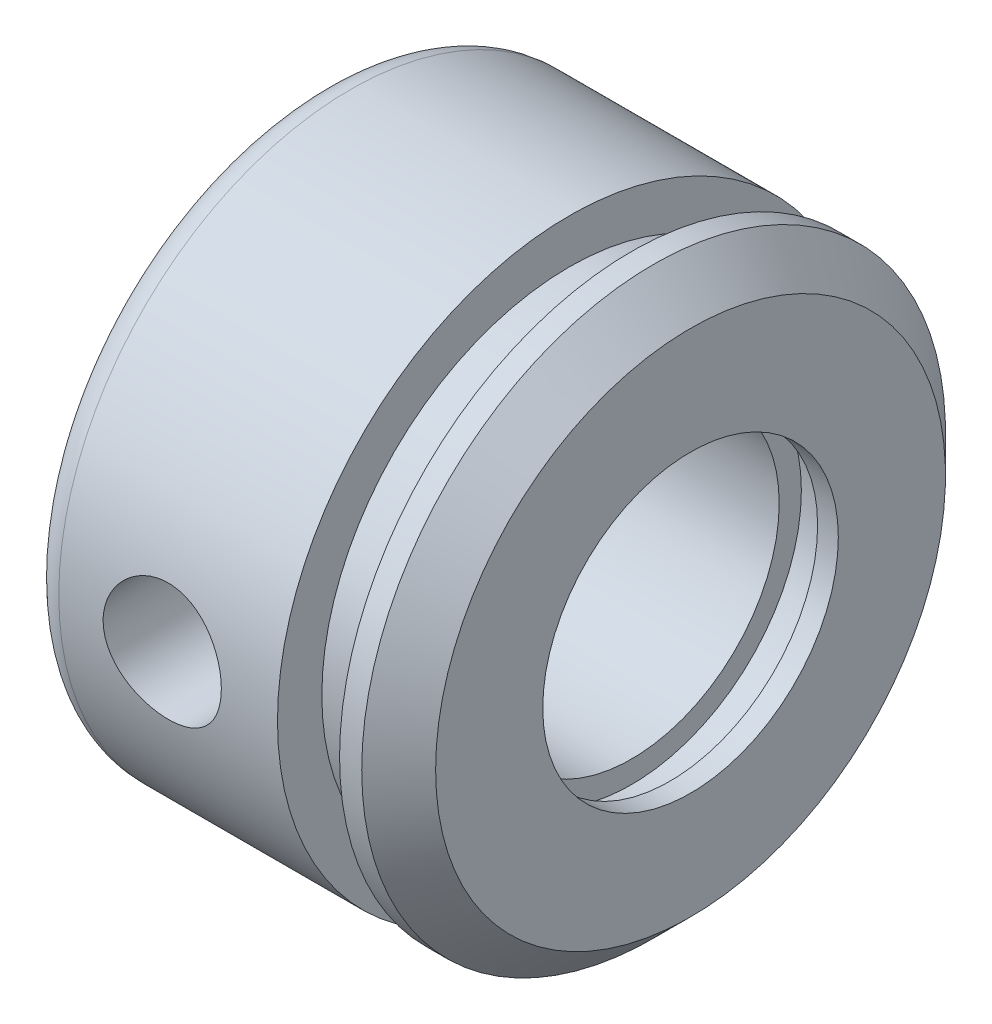
from build123d import *

# Parameters (mm, degrees)
ESQUISSE2_R                  = 4
ENL_V_MAT_EXTRU_1_DEPTH      = 20.75
ENL_V_MAT_EXTRU_1_DEPTH_BACK = 20.75
CONG_2_R                     = 2


with BuildPart() as part:
    # Esquisse1 → Base-Révolution (revolve)
    with BuildSketch(Plane.XY):
        Polygon((-24, 10), (-24, 19.75), (-7.2, 19.75), (-7.2, 16.75), (-3, 16.75), (-3, 19.75), (-1.5, 19.75), (1, 17.25), (1, 10), (-0.4, 10), (-0.4, 11.5), (-3, 11.5), (-3, 10), align=None)
    revolve(axis=Axis((-92, 0, 0), (1, 0, 0)))

    # Esquisse2 → Enlèv. mat.-Extru.1 (cut, two sides)
    with BuildSketch(Plane.XY) as enl_v_mat_extru_1_sk:
        with Locations((-15, 0)):
            Circle(ESQUISSE2_R)
    extrude(amount=ENL_V_MAT_EXTRU_1_DEPTH, mode=Mode.SUBTRACT)
    extrude(enl_v_mat_extru_1_sk.sketch, amount=-ENL_V_MAT_EXTRU_1_DEPTH_BACK, mode=Mode.SUBTRACT)

    # Congé2
    cong_2_edges = [part.edges().sort_by_distance(p)[0] for p in [
        (-24, -19.75, 0),
    ]]
    fillet(cong_2_edges, radius=CONG_2_R)


solid = part.part
